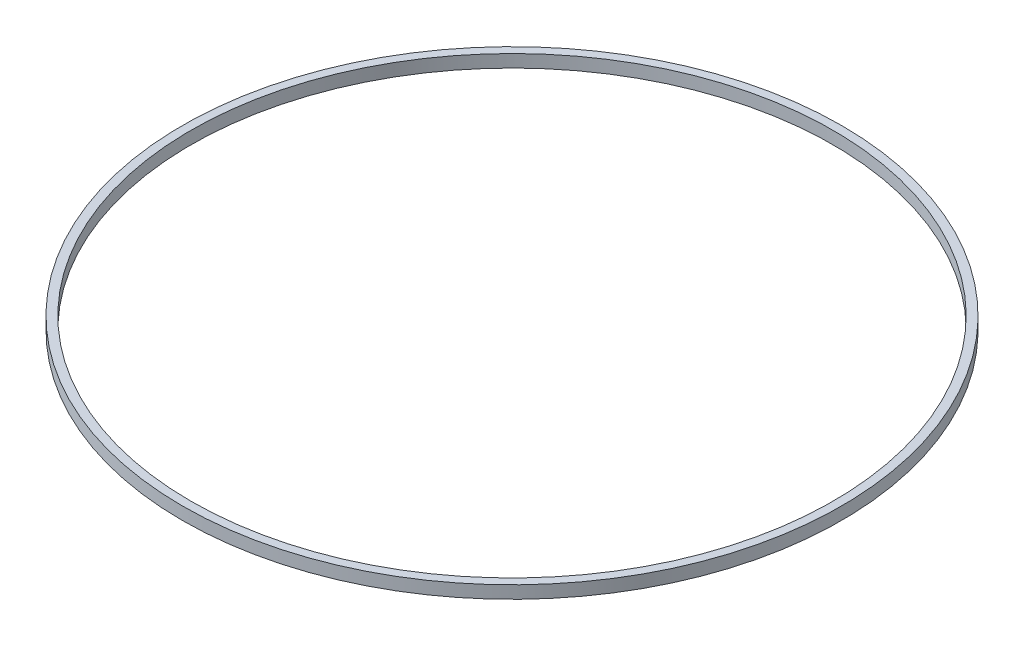
from build123d import *

# Parameters (mm, degrees)
SKETCH1_R               = 78.5
BOSS_EXTRUDE1_DEPTH     = 3
SKETCH2_R               = 76.5
CUT_EXTRUDE1_DEPTH      = 1
CUT_EXTRUDE1_DEPTH_BACK = 4


with BuildPart() as part:
    # Sketch1 → Boss-Extrude1 (new body)
    with BuildSketch(Plane(origin=(0, 0, 0), x_dir=(1, 0, 0), z_dir=(0, 1, 0))):
        Circle(SKETCH1_R)
    extrude(amount=BOSS_EXTRUDE1_DEPTH)

    # Sketch2 → Cut-Extrude1 (cut, two sides)
    with BuildSketch(Plane(origin=(0, 3, 0), x_dir=(1, 0, 0), z_dir=(0, 1, 0))) as cut_extrude1_sk:
        Circle(SKETCH2_R)
    extrude(amount=CUT_EXTRUDE1_DEPTH, mode=Mode.SUBTRACT)
    extrude(cut_extrude1_sk.sketch, amount=-CUT_EXTRUDE1_DEPTH_BACK, mode=Mode.SUBTRACT)


solid = part.part
